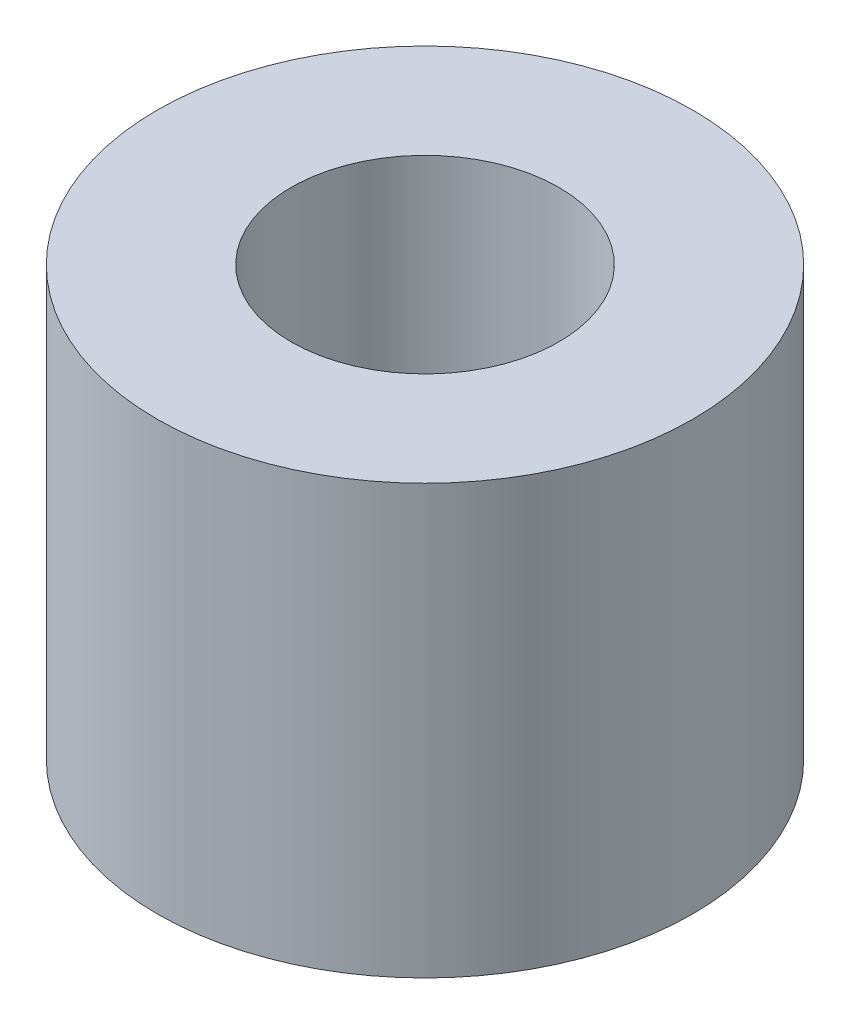
from build123d import *

# Parameters (mm, degrees)
SKETCH1_R           = 6.35
SKETCH1_R_2         = 3.175
BOSS_EXTRUDE1_DEPTH = 10.16


with BuildPart() as part:
    # Sketch1 → Boss-Extrude1 (new body)
    with BuildSketch(Plane(origin=(0, 0, 0), x_dir=(1, 0, 0), z_dir=(0, 1, 0))):
        Circle(SKETCH1_R)
        Circle(SKETCH1_R_2, mode=Mode.SUBTRACT)
    extrude(amount=BOSS_EXTRUDE1_DEPTH)


solid = part.part
